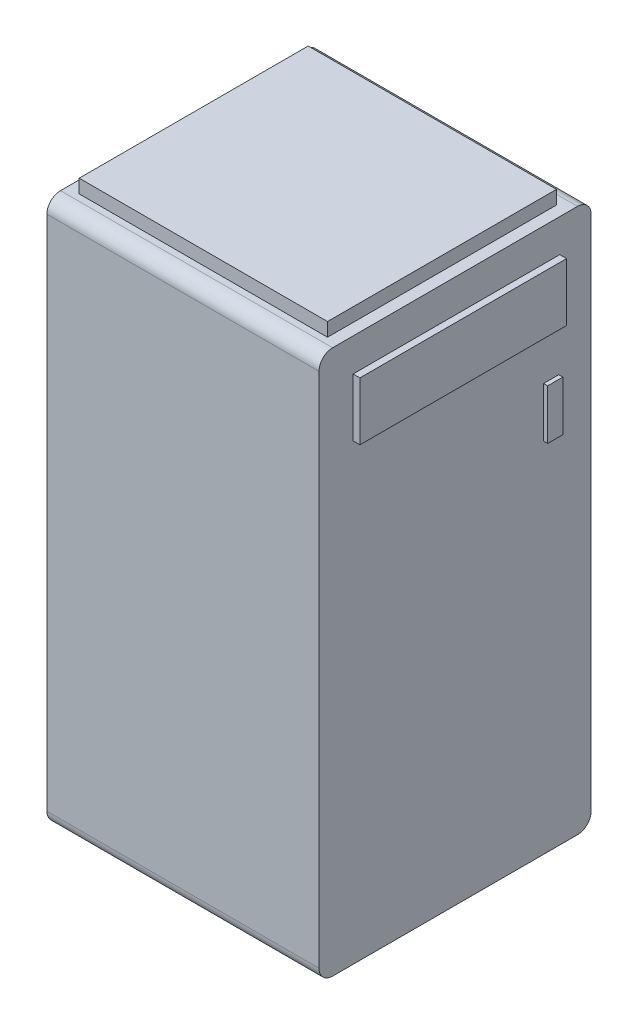
from build123d import *

# Parameters (mm, degrees)
SKETCH1_W           = 200
SKETCH1_H           = 200
BOSS_EXTRUDE1_DEPTH = 400
FILLET1_R           = 10
FILLET2_R           = 10
FILLET3_R           = 10
FILLET4_R           = 10
SKETCH2_W           = 151.890786039
SKETCH2_H           = 42.605964066
BOSS_EXTRUDE2_DEPTH = 5
SKETCH3_W           = 11.177888606
SKETCH3_H           = 36.695974833
BOSS_EXTRUDE3_DEPTH = 3
SKETCH4_W           = 182.495130058
SKETCH4_H           = 168.274128296
CUT_EXTRUDE1_DEPTH  = 350
SKETCH5_W           = 182.495130058
SKETCH5_H           = 168.274128296
CUT_EXTRUDE2_DEPTH  = 175
SKETCH6_W           = 182.495130058
SKETCH6_H           = 168.274128296
BOSS_EXTRUDE4_DEPTH = 10


with BuildPart() as part:
    # Sketch1 → Boss-Extrude1 (new body)
    with BuildSketch(Plane(origin=(0, 0, 0), x_dir=(1, 0, 0), z_dir=(0, 1, 0))):
        with Locations((-100, 100)):
            Rectangle(SKETCH1_W, SKETCH1_H)
    extrude(amount=BOSS_EXTRUDE1_DEPTH)

    # Fillet1
    fillet1_edges = [part.edges().sort_by_distance(p)[0] for p in [
        (-100, 400, 0),
    ]]
    fillet(fillet1_edges, radius=FILLET1_R)

    # Fillet2
    fillet2_edges = [part.edges().sort_by_distance(p)[0] for p in [
        (-100, 400, -200),
    ]]
    fillet(fillet2_edges, radius=FILLET2_R)

    # Fillet3
    fillet3_edges = [part.edges().sort_by_distance(p)[0] for p in [
        (-100, 0, 0),
    ]]
    fillet(fillet3_edges, radius=FILLET3_R)

    # Fillet4
    fillet4_edges = [part.edges().sort_by_distance(p)[0] for p in [
        (-100, 0, -200),
    ]]
    fillet(fillet4_edges, radius=FILLET4_R)

    # Sketch2 → Boss-Extrude2 (add)
    with BuildSketch(Plane(origin=(0, 0, 0), x_dir=(0, 0, -1), z_dir=(1, 0, 0))):
        with Locations((101.017573134, 354.479134096)):
            Rectangle(SKETCH2_W, SKETCH2_H)
    extrude(amount=BOSS_EXTRUDE2_DEPTH)

    # Sketch3 → Boss-Extrude3 (add)
    with BuildSketch(Plane(origin=(0, 0, 0), x_dir=(0, 0, -1), z_dir=(1, 0, 0))):
        with Locations((170.659301247, 281.368641249)):
            Rectangle(SKETCH3_W, SKETCH3_H)
    extrude(amount=BOSS_EXTRUDE3_DEPTH)

    # Sketch4 → Cut-Extrude1 (cut)
    with BuildSketch(Plane(origin=(0, 400, 0), x_dir=(1, 0, 0), z_dir=(0, 1, 0))):
        with Locations((-99.808413428, 98.946230153)):
            Rectangle(SKETCH4_W, SKETCH4_H)
    extrude(amount=-CUT_EXTRUDE1_DEPTH, mode=Mode.SUBTRACT)

    # Sketch5 → Cut-Extrude2 (cut)
    with BuildSketch(Plane(origin=(0, 50, 0), x_dir=(1, 0, 0), z_dir=(0, 1, 0))):
        with Locations((-99.808413428, 98.946230153)):
            Rectangle(SKETCH5_W, SKETCH5_H)
    extrude(amount=-CUT_EXTRUDE2_DEPTH, mode=Mode.SUBTRACT)


with BuildPart() as body_2:
    # Sketch6 → Boss-Extrude4 (new body)
    with BuildSketch(Plane(origin=(0, 400, 0), x_dir=(1, 0, 0), z_dir=(0, 1, 0))):
        with Locations((-99.808413428, 98.946230153)):
            Rectangle(SKETCH6_W, SKETCH6_H)
    extrude(amount=BOSS_EXTRUDE4_DEPTH)


solid = Compound([part.part, body_2.part])
